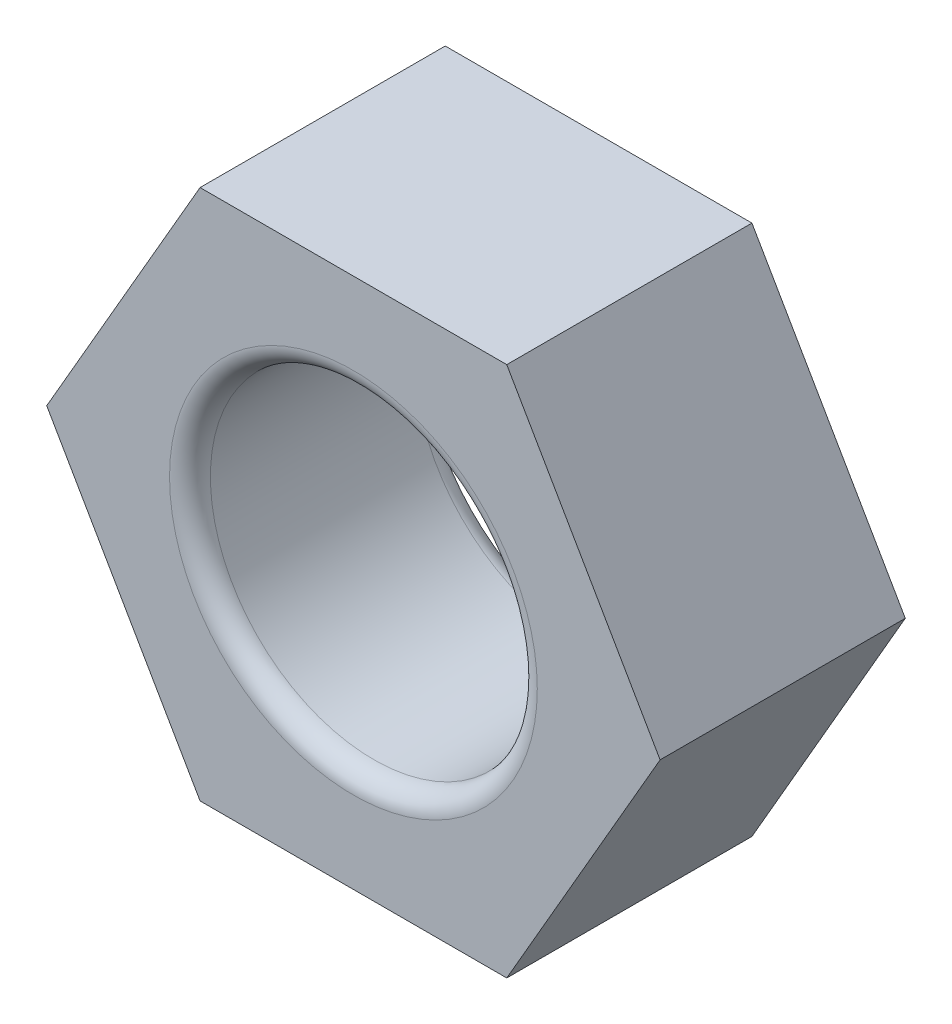
from build123d import *

# Parameters (mm, degrees)
ESQUISSE1_R      = 4
EXTRUSION1_DEPTH = 6
CONG_1_R         = 0.5


with BuildPart() as part:
    # Esquisse1 → Extrusion1 (new body)
    with BuildSketch(Plane.XY):
        Polygon((7.505553499, 0), (3.75277675, 6.5), (-3.75277675, 6.5), (-7.505553499, 0), (-3.75277675, -6.5), (3.75277675, -6.5), align=None)
        Circle(ESQUISSE1_R, mode=Mode.SUBTRACT)
    extrude(amount=EXTRUSION1_DEPTH)

    # Congé1
    cong_1_edges = [part.edges().sort_by_distance(p)[0] for p in [
        (-4, 0, 0),
        (-4, 0, 6),
    ]]
    fillet(cong_1_edges, radius=CONG_1_R)


solid = part.part
